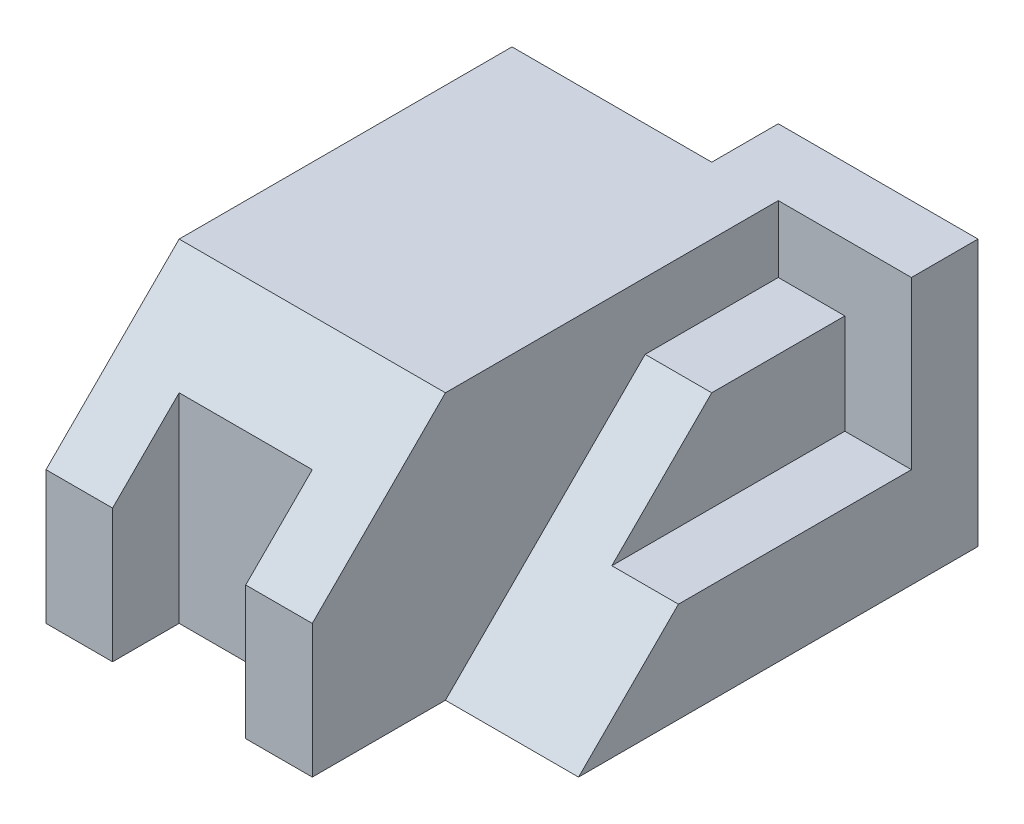
from build123d import *

# Parameters (mm, degrees)
BOSS_EXTRUDE1_DEPTH = 40
CHAMFER1_SIZE       = 20
CUT_EXTRUDE1_DEPTH  = 20
SKETCH3_W           = 10
SKETCH3_H           = 15
CUT_EXTRUDE2_DEPTH  = 70


with BuildPart() as part:
    # Sketch1 → Boss-Extrude1 (new body)
    with BuildSketch(Plane(origin=(0, 0, 0), x_dir=(1, 0, 0), z_dir=(0, 1, 0))):
        Polygon((0, 0), (30, 0), (30, 10), (60, 10), (60, -60), (40, -60), (40, -70), (30, -70), (30, -60), (10, -60), (10, -70), (0, -70), align=None)
    extrude(amount=BOSS_EXTRUDE1_DEPTH)

    # Chamfer1
    chamfer1_edges = [part.edges().sort_by_distance(p)[0] for p in [
        (5, 40, 70),
    ]]
    chamfer(chamfer1_edges, length=CHAMFER1_SIZE)

    # Sketch2 → Cut-Extrude1 (cut)
    with BuildSketch(Plane(origin=(60, 0, 0), x_dir=(0, 0, -1), z_dir=(1, 0, 0))):
        Polygon((0, 30), (0, 40), (-50, 40), (-60, 30), (-60, 0), (-50, 0), (-20, 30), align=None)
    extrude(amount=-CUT_EXTRUDE1_DEPTH, mode=Mode.SUBTRACT)

    # Sketch3 → Cut-Extrude2 (cut)
    with BuildSketch(Plane.XY.offset(70)):
        with Locations((55, 22.5)):
            Rectangle(SKETCH3_W, SKETCH3_H)
    extrude(amount=-CUT_EXTRUDE2_DEPTH, mode=Mode.SUBTRACT)


solid = part.part
